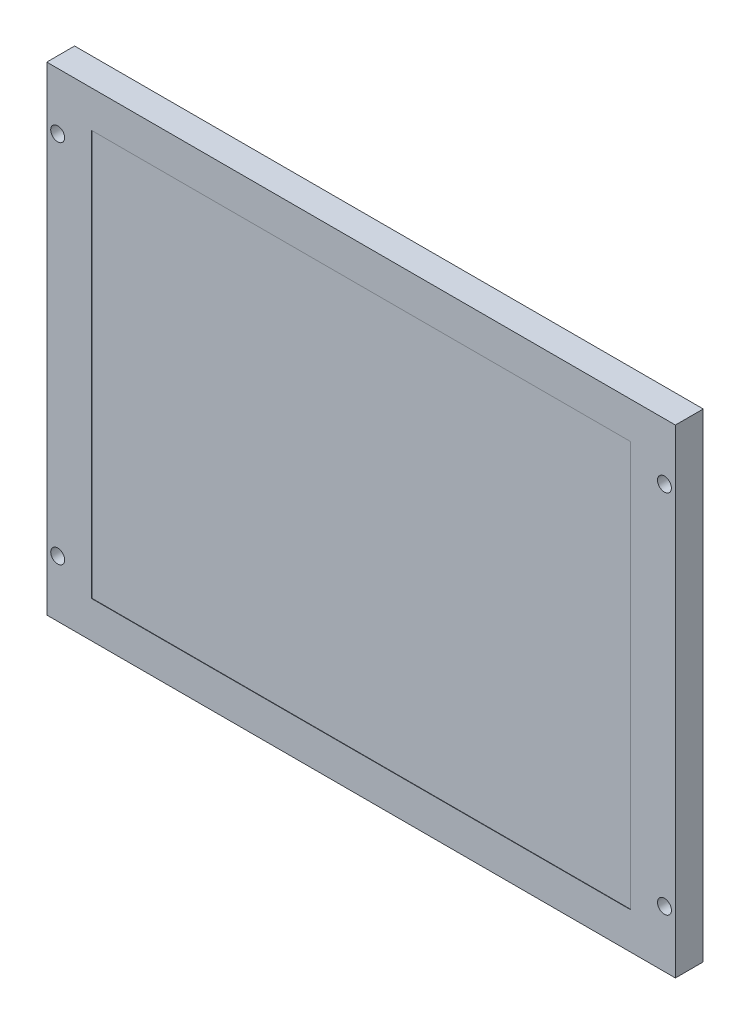
from build123d import *

# Parameters (mm, degrees)
SKETCH1_W                  = 158
SKETCH1_H                  = 120.36
EXTRUDE1_DEPTH             = 7
SKETCH2_W                  = 135.46
SKETCH2_H                  = 101.9
BEZEL_OPENING_DEPTH        = 0.1
SKETCH3_R                  = 1.75
MOUNT_HOLE_CUT_DEPTH       = 10
SKETCH4_W                  = 19.642579642
SKETCH4_H                  = 3.682983682
HIROSE_DF9_CONNECTOR_DEPTH = 3.75


with BuildPart() as part:
    # Sketch1 → Extrude1 (new body)
    with BuildSketch(Plane.XY):
        with Locations((79, -60.18)):
            Rectangle(SKETCH1_W, SKETCH1_H)
    extrude(amount=EXTRUDE1_DEPTH)

    # Sketch2 → Bezel Opening (cut)
    with BuildSketch(Plane.XY.offset(7)):
        with Locations((79, -60.18)):
            Rectangle(SKETCH2_W, SKETCH2_H)
    extrude(amount=-BEZEL_OPENING_DEPTH, mode=Mode.SUBTRACT)

    # Sketch3 → Mount hole cut (cut)
    with BuildSketch(Plane.XY.offset(7)):
        with Locations((155.25, -14.23)):
            Circle(SKETCH3_R)
        with Locations((155.25, -106.13)):
            Circle(SKETCH3_R)
        with Locations((2.75, -14.23)):
            Circle(SKETCH3_R)
        with Locations((2.75, -106.13)):
            Circle(SKETCH3_R)
    extrude(amount=-MOUNT_HOLE_CUT_DEPTH, mode=Mode.SUBTRACT)

    # Sketch4 → Hirose DF9 connector (add)
    with BuildSketch(Plane(origin=(0, 0, 0), x_dir=(-1, 0, 0), z_dir=(0, 0, -1))):
        with Locations((-132.75, -77.66)):
            Rectangle(SKETCH4_W, SKETCH4_H)
    extrude(amount=HIROSE_DF9_CONNECTOR_DEPTH)


solid = part.part
